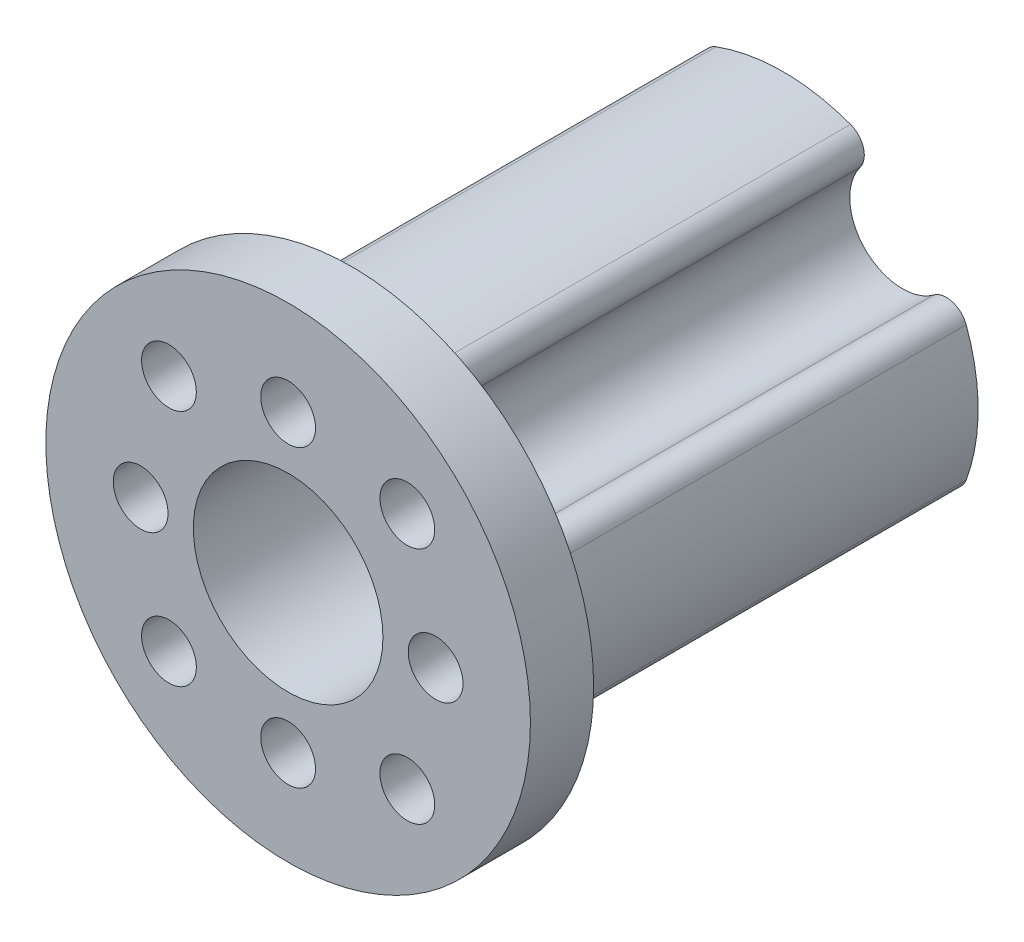
from build123d import *

# Parameters (mm, degrees)
ESQUISSE1_R                  = 9.25
BOSS_EXTRU_1_DEPTH           = 23.5
ESQUISSE2_R                  = 1.3
ENL_V_MAT_EXTRU_1_DEPTH      = 1
ENL_V_MAT_EXTRU_1_DEPTH_BACK = 24.5
ESQUISSE3_R                  = 4.5
ENL_V_MAT_EXTRU_2_DEPTH      = 1
ENL_V_MAT_EXTRU_2_DEPTH_BACK = 24.5
ESQUISSE4_R                  = 11.5
ESQUISSE4_R_2                = 9.25
BOSS_EXTRU_2_DEPTH           = 3
ESQUISSE5_R                  = 2.5
ENL_V_MAT_EXTRU_3_DEPTH      = 1
ENL_V_MAT_EXTRU_3_DEPTH_BACK = 24.5
BOSS_EXTRU_3_START           = -3
ESQUISSE6_R                  = 2.5
ESQUISSE6_R_2                = 1.3
BOSS_EXTRU_3_DEPTH           = 3
CONG_1_R                     = 1


with BuildPart() as part:
    # Esquisse1 → Boss.-Extru.1 (new body)
    with BuildSketch(Plane.XY):
        Circle(ESQUISSE1_R)
    extrude(amount=BOSS_EXTRU_1_DEPTH)

    # Esquisse2 → Enlèv. mat.-Extru.1 (cut, two sides)
    with BuildSketch(Plane.XY.offset(23.5)) as enl_v_mat_extru_1_sk:
        with Locations((7, 0)):
            Circle(ESQUISSE2_R)
        with Locations((0, -7)):
            Circle(ESQUISSE2_R)
        with Locations((-7, 0)):
            Circle(ESQUISSE2_R)
        with Locations((0, 7)):
            Circle(ESQUISSE2_R)
    extrude(amount=ENL_V_MAT_EXTRU_1_DEPTH, mode=Mode.SUBTRACT)
    extrude(enl_v_mat_extru_1_sk.sketch, amount=-ENL_V_MAT_EXTRU_1_DEPTH_BACK, mode=Mode.SUBTRACT)

    # Esquisse3 → Enlèv. mat.-Extru.2 (cut, two sides)
    with BuildSketch(Plane.XY.offset(23.5)) as enl_v_mat_extru_2_sk:
        Circle(ESQUISSE3_R)
    extrude(amount=ENL_V_MAT_EXTRU_2_DEPTH, mode=Mode.SUBTRACT)
    extrude(enl_v_mat_extru_2_sk.sketch, amount=-ENL_V_MAT_EXTRU_2_DEPTH_BACK, mode=Mode.SUBTRACT)

    # Esquisse4 → Boss.-Extru.2 (add)
    with BuildSketch(Plane.XY.offset(23.5)):
        Circle(ESQUISSE4_R)
        Circle(ESQUISSE4_R_2, mode=Mode.SUBTRACT)
    extrude(amount=-BOSS_EXTRU_2_DEPTH)

    # Esquisse5 → Enlèv. mat.-Extru.3 (cut, two sides)
    with BuildSketch(Plane.XY.offset(23.5)) as enl_v_mat_extru_3_sk:
        with Locations((5.656854249, 5.656854249)):
            Circle(ESQUISSE5_R)
        with Locations((5.656854249, -5.656854249)):
            Circle(ESQUISSE5_R)
        with Locations((-5.656854249, -5.656854249)):
            Circle(ESQUISSE5_R)
        with Locations((-5.656854249, 5.656854249)):
            Circle(ESQUISSE5_R)
    extrude(amount=ENL_V_MAT_EXTRU_3_DEPTH, mode=Mode.SUBTRACT)
    extrude(enl_v_mat_extru_3_sk.sketch, amount=-ENL_V_MAT_EXTRU_3_DEPTH_BACK, mode=Mode.SUBTRACT)

    # Esquisse6 → Boss.-Extru.3 (add)
    with BuildSketch(Plane.XY.offset(23.5).offset(BOSS_EXTRU_3_START)):
        with Locations((-5.656854249, 5.656854249)):
            Circle(ESQUISSE6_R)
        with Locations((-5.656854249, 5.656854249)):
            Circle(ESQUISSE6_R_2, mode=Mode.SUBTRACT)
        with Locations((5.656854249, 5.656854249)):
            Circle(ESQUISSE6_R)
        with Locations((5.656854249, 5.656854249)):
            Circle(ESQUISSE6_R_2, mode=Mode.SUBTRACT)
        with Locations((5.656854249, -5.656854249)):
            Circle(ESQUISSE6_R)
        with Locations((5.656854249, -5.656854249)):
            Circle(ESQUISSE6_R_2, mode=Mode.SUBTRACT)
        with Locations((-5.656854249, -5.656854249)):
            Circle(ESQUISSE6_R)
        with Locations((-5.656854249, -5.656854249)):
            Circle(ESQUISSE6_R_2, mode=Mode.SUBTRACT)
    extrude(amount=BOSS_EXTRU_3_DEPTH)

    # Congé1
    cong_1_edges = [part.edges().sort_by_distance(p)[0] for p in [
        (7.966686716, 4.700468356, 10.25),
        (4.700468356, 7.966686716, 10.25),
        (4.700468356, -7.966686716, 10.25),
        (7.966686716, -4.700468356, 10.25),
        (-7.966686716, -4.700468356, 10.25),
        (-4.700468356, -7.966686716, 10.25),
        (-4.700468356, 7.966686716, 10.25),
        (-7.966686716, 4.700468356, 10.25),
    ]]
    fillet(cong_1_edges, radius=CONG_1_R)


solid = part.part
